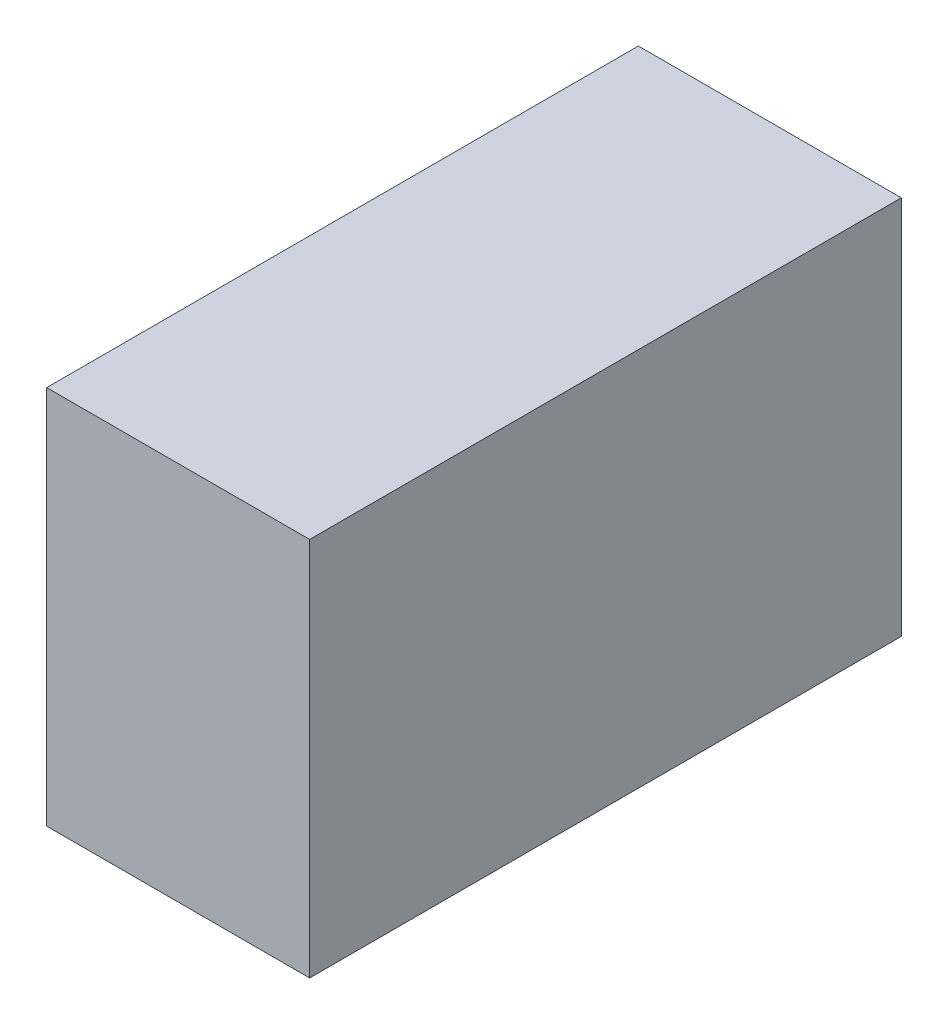
from build123d import *

# Parameters (mm, degrees)
SKETCH1_W           = 25.4
SKETCH1_H           = 36.68776
BOSS_EXTRUDE1_DEPTH = 57.15


with BuildPart() as part:
    # Sketch1 → Boss-Extrude1 (new body)
    with BuildSketch(Plane.XY):
        with Locations((12.7, 18.34388)):
            Rectangle(SKETCH1_W, SKETCH1_H)
    extrude(amount=BOSS_EXTRUDE1_DEPTH)


solid = part.part
